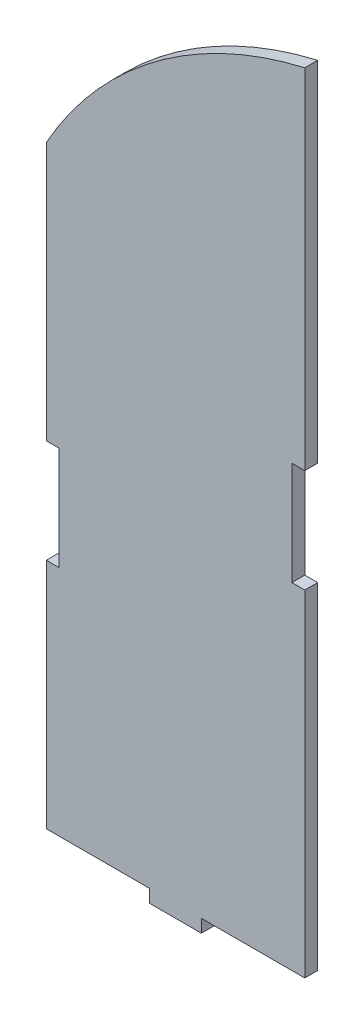
from build123d import *

# Parameters (mm, degrees)
BOSS_EXTRU_1_DEPTH = 5


with BuildPart() as part:
    # Esquisse1 → Boss.-Extru.1 (new body)
    with BuildSketch(Plane.XY):
        with BuildLine():
            Line((100, 145.707319285), (100, 240.707319285))
            Line((100, 240.707319285), (100, 275.707319285))
            Line((100, 275.707319285), (95, 275.707319285))
            Line((95, 275.707319285), (95, 315.707319285))
            Line((95, 315.707319285), (100, 315.707319285))
            Line((100, 315.707319285), (100, 450.707319285))
            ThreePointArc((100, 450.707319285), (42.075716698, 423.773030355), (0, 375.707319285))
            Line((0, 375.707319285), (0, 275.707319285))
            Line((0, 275.707319285), (5, 275.707319285))
            Line((5, 275.707319285), (5, 235.707319285))
            Line((5, 235.707319285), (0, 235.707319285))
            Line((0, 235.707319285), (0, 145.707319285))
            Line((0, 145.707319285), (40, 145.707319285))
            Line((40, 145.707319285), (40, 140.707319285))
            Line((40, 140.707319285), (60, 140.707319285))
            Line((60, 140.707319285), (60, 145.707319285))
            Line((60, 145.707319285), (100, 145.707319285))
        make_face()
    extrude(amount=BOSS_EXTRU_1_DEPTH)


solid = part.part
